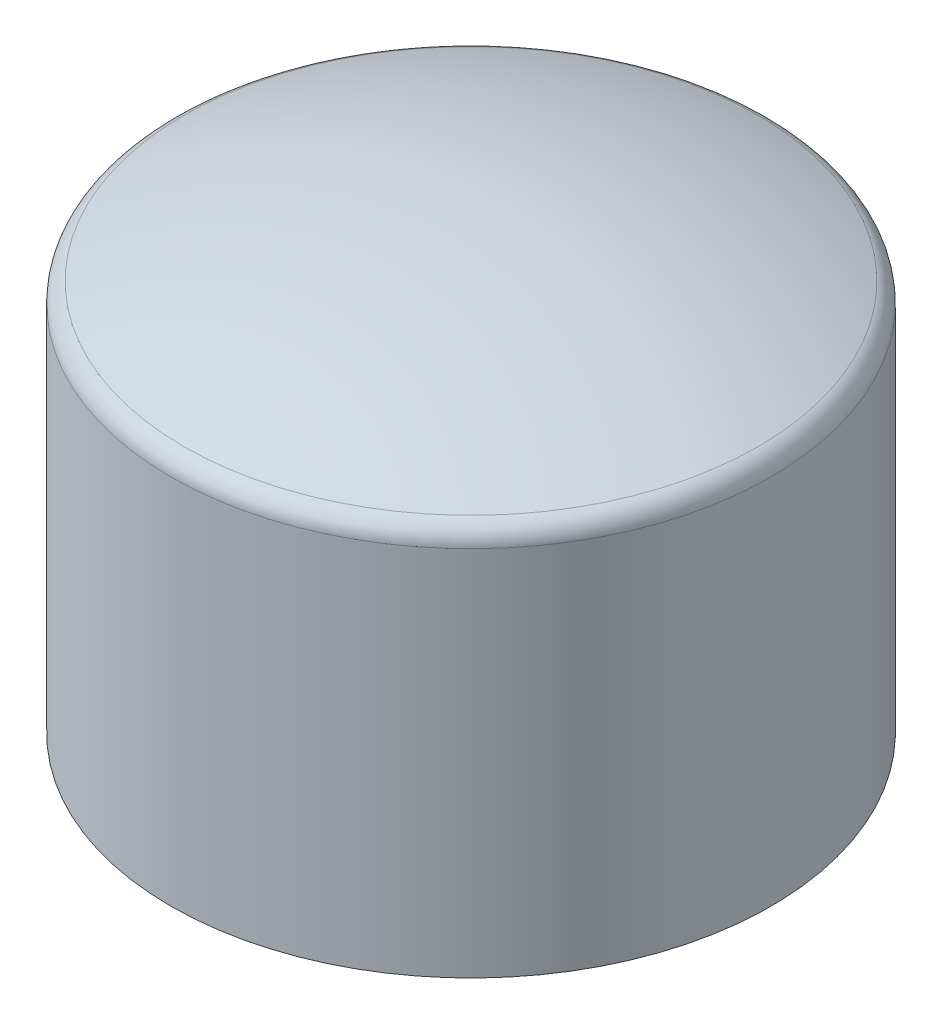
from build123d import *

# Parameters (mm, degrees)
FILLET1_R = 0.5


with BuildPart() as part:
    # Sketch2 → Revolve1 (revolve)
    with BuildSketch(Plane(origin=(0, 0, 0), x_dir=(0, 0, -1), z_dir=(1, 0, 0))):
        with BuildLine():
            Line((0, 0), (7, 0))
            Line((7, 0), (7, 9))
            ThreePointArc((7, 9), (3.579455266, 10.12079124), (0, 10.5))
            Line((0, 10.5), (0, 0))
        make_face()
    revolve(axis=Axis((0, 0, 0), (0, 1, 0)))

    # Fillet1
    fillet1_edges = [part.edges().sort_by_distance(p)[0] for p in [
        (0, 9, 7),
    ]]
    fillet(fillet1_edges, radius=FILLET1_R)


solid = part.part
